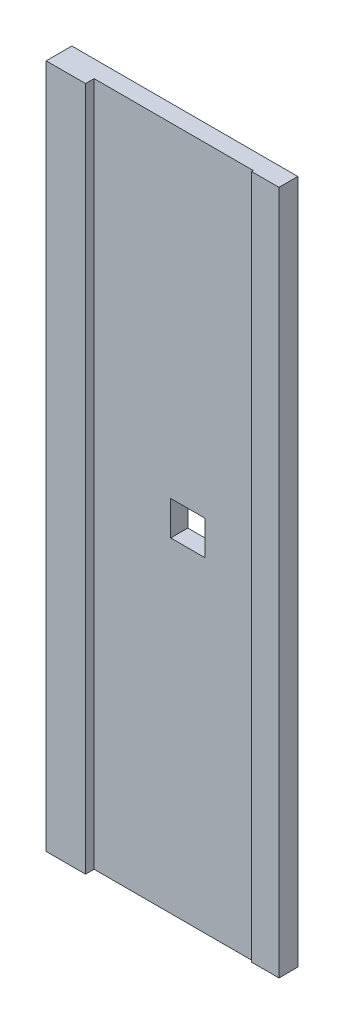
from build123d import *

# Parameters (mm, degrees)
SKETCH_1_W          = 132
SKETCH_1_H          = 400
EXTRUDE_1_DEPTH     = 10
SKETCH_2_W          = 23
SKETCH_2_H          = 400
EXTRUDE_2_DEPTH     = 5
SKETCH_3_W          = 16
SKETCH_3_H          = 400
EXTRUDE_3_DEPTH     = 1
SKETCH_4_W          = 20
SKETCH_4_H          = 20
CUT_EXTRUDE_1_DEPTH = 11


with BuildPart() as part:
    # ｽｹｯﾁ1 → ﾎﾞｽ - 押し出し1 (new body)
    with BuildSketch(Plane.XY):
        with Locations((66, 200)):
            Rectangle(SKETCH_1_W, SKETCH_1_H)
    extrude(amount=EXTRUDE_1_DEPTH)

    # ｽｹｯﾁ2 → ﾎﾞｽ - 押し出し2 (add)
    with BuildSketch(Plane.XY.offset(10)):
        with Locations((11.5, 200)):
            Rectangle(SKETCH_2_W, SKETCH_2_H)
    extrude(amount=EXTRUDE_2_DEPTH)

    # ｽｹｯﾁ3 → ﾎﾞｽ - 押し出し3 (add)
    with BuildSketch(Plane.XY.offset(10)):
        with Locations((124, 200)):
            Rectangle(SKETCH_3_W, SKETCH_3_H)
    extrude(amount=EXTRUDE_3_DEPTH)

    # ｽｹｯﾁ4 → ｶｯﾄ - 押し出し1 (cut, through all)
    with BuildSketch(Plane.XY.offset(10)):
        with Locations((77.75, 200)):
            Rectangle(SKETCH_4_W, SKETCH_4_H)
    extrude(amount=-CUT_EXTRUDE_1_DEPTH, mode=Mode.SUBTRACT)


solid = part.part
